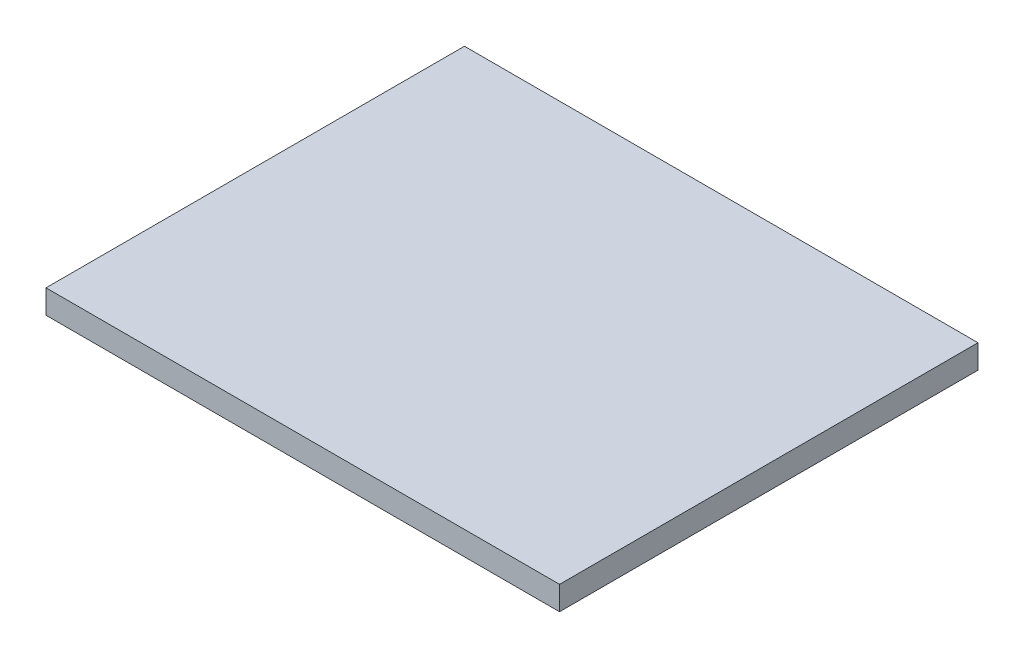
from build123d import *

# Parameters (mm, degrees)
SKETCH1_W           = 64.8
SKETCH1_H           = 3
BOSS_EXTRUDE1_DEPTH = 52.8


with BuildPart() as part:
    # Sketch1 → Boss-Extrude1 (new body)
    with BuildSketch(Plane.XY):
        with Locations((32.4, -101.5)):
            Rectangle(SKETCH1_W, SKETCH1_H)
    extrude(amount=BOSS_EXTRUDE1_DEPTH)


solid = part.part
